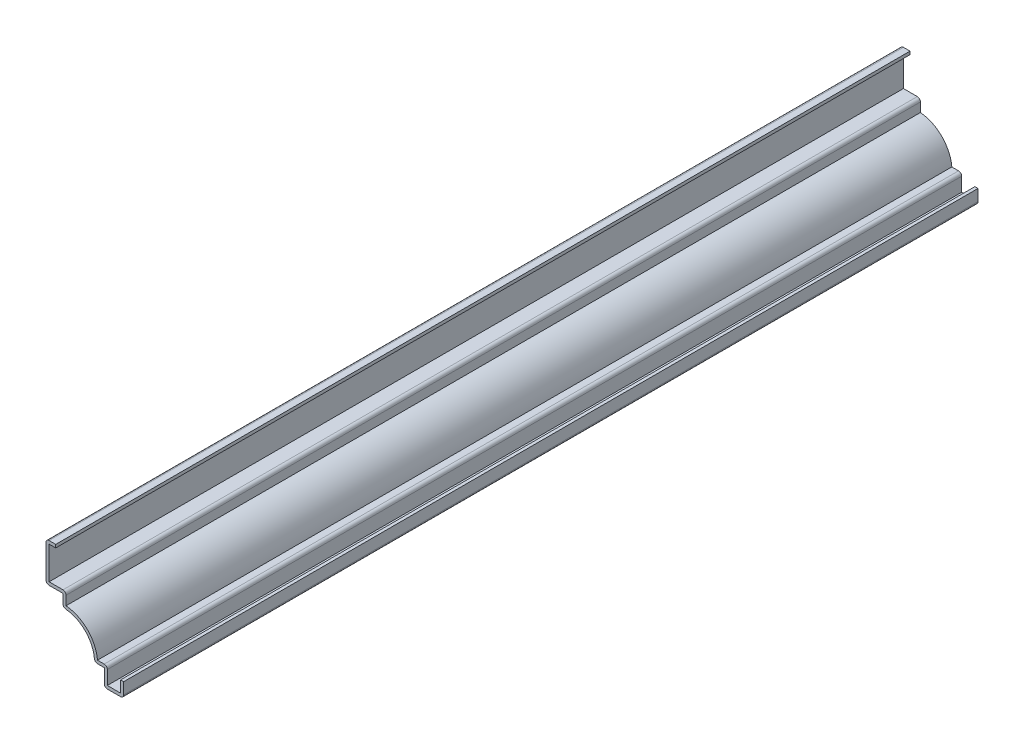
from build123d import *

# Parameters (mm, degrees)
EXTRUDE_THIN1_DEPTH = 279.4
FILLET1_R           = 1.016


with BuildPart() as part:
    # Sketch1 → Extrude-Thin1 (new body)
    with BuildSketch(Plane.XY):
        with BuildLine():
            Line((0, 4.7625), (0, 0))
            Line((0, 0), (-6.35, 0))
            Line((-6.35, 0), (-6.35, 5.55625))
            Line((-6.35, 5.55625), (-9.525, 5.55625))
            ThreePointArc((-9.525, 5.55625), (-12.547291902, 12.852708098), (-19.84375, 15.875))
            Line((-19.84375, 15.875), (-19.84375, 19.84375))
            Line((-19.84375, 19.84375), (-25.4, 19.84375))
            Line((-25.4, 19.84375), (-25.4, 32.54375))
            Line((-25.4, 32.54375), (-22.225, 32.54375))
            Line((-22.225, 32.54375), (-22.225, 31.52775))
            Line((-22.225, 31.52775), (-24.384, 31.52775))
            Line((-24.384, 31.52775), (-24.384, 20.85975))
            Line((-24.384, 20.85975), (-18.82775, 20.85975))
            Line((-18.82775, 20.85975), (-18.82775, 16.845373153))
            ThreePointArc((-18.82775, 16.845373153), (-11.828871412, 13.571128588), (-8.554626847, 6.57225))
            Line((-8.554626847, 6.57225), (-5.334, 6.57225))
            Line((-5.334, 6.57225), (-5.334, 1.016))
            Line((-5.334, 1.016), (-1.016, 1.016))
            Line((-1.016, 1.016), (-1.016, 4.7625))
            Line((-1.016, 4.7625), (0, 4.7625))
        make_face()
    extrude(amount=-EXTRUDE_THIN1_DEPTH)

    # Fillet1
    fillet1_edges = [part.edges().sort_by_distance(p)[0] for p in [
        (-18.82775, 20.85975, -139.7),
        (-5.334, 6.57225, -139.7),
        (0, 0, -139.7),
        (-6.35, 0, -139.7),
        (-9.525, 5.55625, -139.7),
        (-19.84375, 15.875, -139.7),
        (-25.4, 19.84375, -139.7),
        (-25.4, 32.54375, -139.7),
    ]]
    fillet(fillet1_edges, radius=FILLET1_R)


solid = part.part
